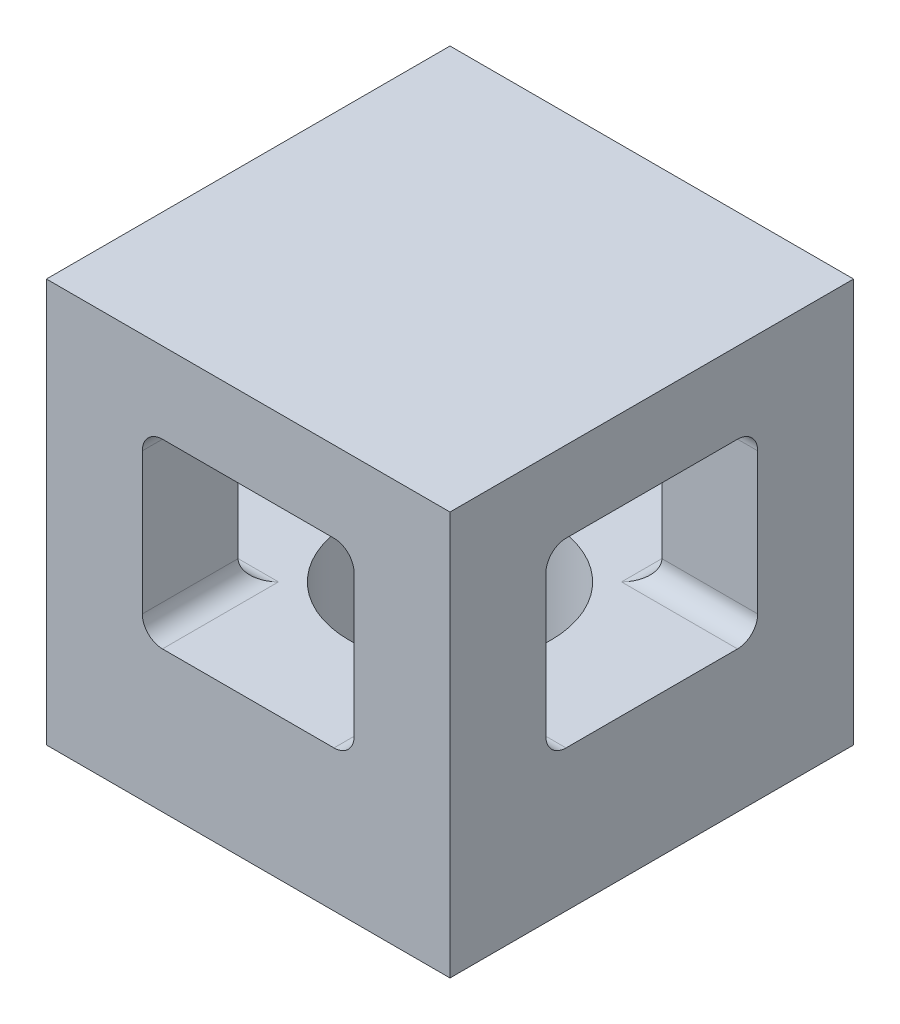
from build123d import *

# Parameters (mm, degrees)
SKETCH2_W           = 10.16
SKETCH2_H           = 10.16
BOSS_EXTRUDE1_DEPTH = 10.16
SKETCH3_R           = 2.54
CUT_EXTRUDE1_DEPTH  = 8.128
CUT_EXTRUDE2_DEPTH  = 10.16
CUT_EXTRUDE3_DEPTH  = 10.16


with BuildPart() as part:
    # Sketch2 → Boss-Extrude1 (new body)
    with BuildSketch(Plane(origin=(0, 0, 0), x_dir=(1, 0, 0), z_dir=(0, 1, 0))):
        with Locations((5.08, 5.08)):
            Rectangle(SKETCH2_W, SKETCH2_H)
    extrude(amount=BOSS_EXTRUDE1_DEPTH)

    # Sketch3 → Cut-Extrude1 (cut)
    with BuildSketch(Plane(origin=(0, 0, 0), x_dir=(-1, 0, 0), z_dir=(0, -1, 0))):
        with Locations((-5.08, 5.08)):
            Circle(SKETCH3_R)
    extrude(amount=-CUT_EXTRUDE1_DEPTH, mode=Mode.SUBTRACT)

    # Sketch6 → Cut-Extrude2 (cut)
    with BuildSketch(Plane(origin=(10.16, 0, 0), x_dir=(0, 0, -1), z_dir=(1, 0, 0))):
        with BuildLine():
            Line((2.921, 8.128), (7.239, 8.128))
            ThreePointArc((7.239, 8.128), (7.598210245, 7.979210245), (7.747, 7.62))
            Line((7.747, 7.62), (7.747, 4.064))
            ThreePointArc((7.747, 4.064), (7.598210245, 3.704789755), (7.239, 3.556))
            Line((7.239, 3.556), (2.921, 3.556))
            ThreePointArc((2.921, 3.556), (2.561789755, 3.704789755), (2.413, 4.064))
            Line((2.413, 4.064), (2.413, 7.62))
            ThreePointArc((2.413, 7.62), (2.561789755, 7.979210245), (2.921, 8.128))
        make_face()
    extrude(amount=-CUT_EXTRUDE2_DEPTH, mode=Mode.SUBTRACT)

    # Sketch4 → Cut-Extrude3 (cut)
    with BuildSketch(Plane.XY):
        with BuildLine():
            Line((2.921, 8.128), (7.239, 8.128))
            ThreePointArc((7.239, 8.128), (7.598210245, 7.979210245), (7.747, 7.62))
            Line((7.747, 7.62), (7.747, 4.064))
            ThreePointArc((7.747, 4.064), (7.598210245, 3.704789755), (7.239, 3.556))
            Line((7.239, 3.556), (2.921, 3.556))
            ThreePointArc((2.921, 3.556), (2.561789755, 3.704789755), (2.413, 4.064))
            Line((2.413, 4.064), (2.413, 7.62))
            ThreePointArc((2.413, 7.62), (2.561789755, 7.979210245), (2.921, 8.128))
        make_face()
    extrude(amount=-CUT_EXTRUDE3_DEPTH, mode=Mode.SUBTRACT)


solid = part.part
